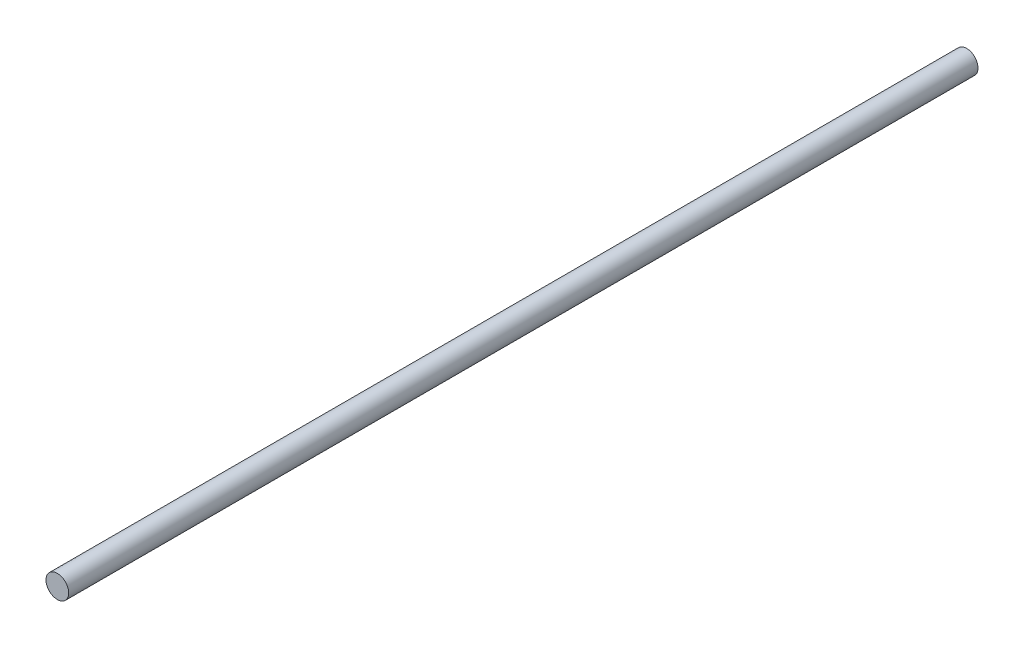
from build123d import *

# Parameters (mm, degrees)
SKETCH1_R           = 3.175
BOSS_EXTRUDE1_DEPTH = 254


with BuildPart() as part:
    # Sketch1 → Boss-Extrude1 (new body)
    with BuildSketch(Plane.XY):
        Circle(SKETCH1_R)
    extrude(amount=BOSS_EXTRUDE1_DEPTH)


solid = part.part
